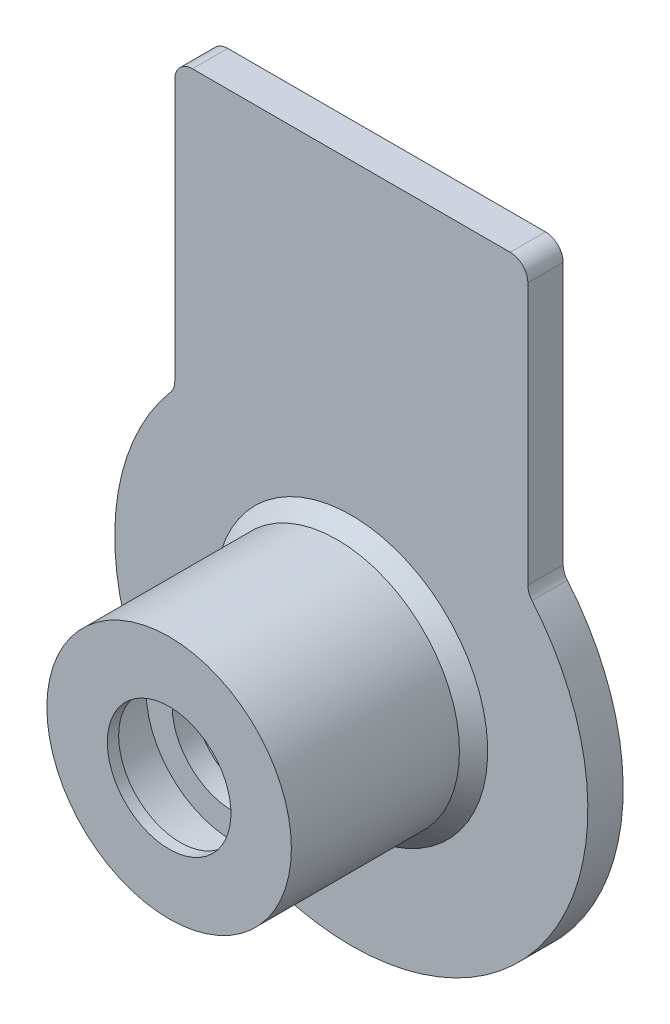
from build123d import *

# Parameters (mm, degrees)
BOSS_EXTRUDE1_DEPTH = 2
FILLET2_R           = 1
CHAMFER1_SIZE       = 0.8


with BuildPart() as part:
    # Sketch2 → Revolve1 (revolve)
    with BuildSketch(Plane(origin=(0, 0, 0), x_dir=(1, 0, 0), z_dir=(0, 1, 0))):
        Polygon((-3.5, -12.32), (-3.5, -11.68), (-4.925, -11.2), (-4.925, -8.7), (-3.45, -8.7), (-3.45, -7.5), (-5, -7.5), (-5, 0), (-13.4, 0), (-13.4, -2), (-6.925, -2), (-6.925, -12.32), align=None)
    revolve(axis=Axis((0, 0, 0), (0, 0, 1)))

    # Sketch3 → Boss-Extrude1 (add)
    with BuildSketch(Plane.XY.offset(2)):
        with BuildLine():
            Line((10, 8.919641248), (10, 25.121576202))
            Line((10, 25.121576202), (-10, 25.121576202))
            Line((-10, 25.121576202), (-10, 8.919641248))
            ThreePointArc((-10, 8.919641248), (0, 13.4), (10, 8.919641248))
        make_face()
    extrude(amount=-BOSS_EXTRUDE1_DEPTH)

    # Fillet2
    fillet2_edges = [part.edges().sort_by_distance(p)[0] for p in [
        (10, 25.121576202, 1),
        (-10, 25.121576202, 1),
        (-10, 8.919641248, 1),
        (10, 8.919641248, 1),
    ]]
    fillet(fillet2_edges, radius=FILLET2_R)

    # Chamfer1
    chamfer1_edges = [part.edges().sort_by_distance(p)[0] for p in [
        (6.925, 0, 2),
    ]]
    chamfer(chamfer1_edges, length=CHAMFER1_SIZE)


solid = part.part
